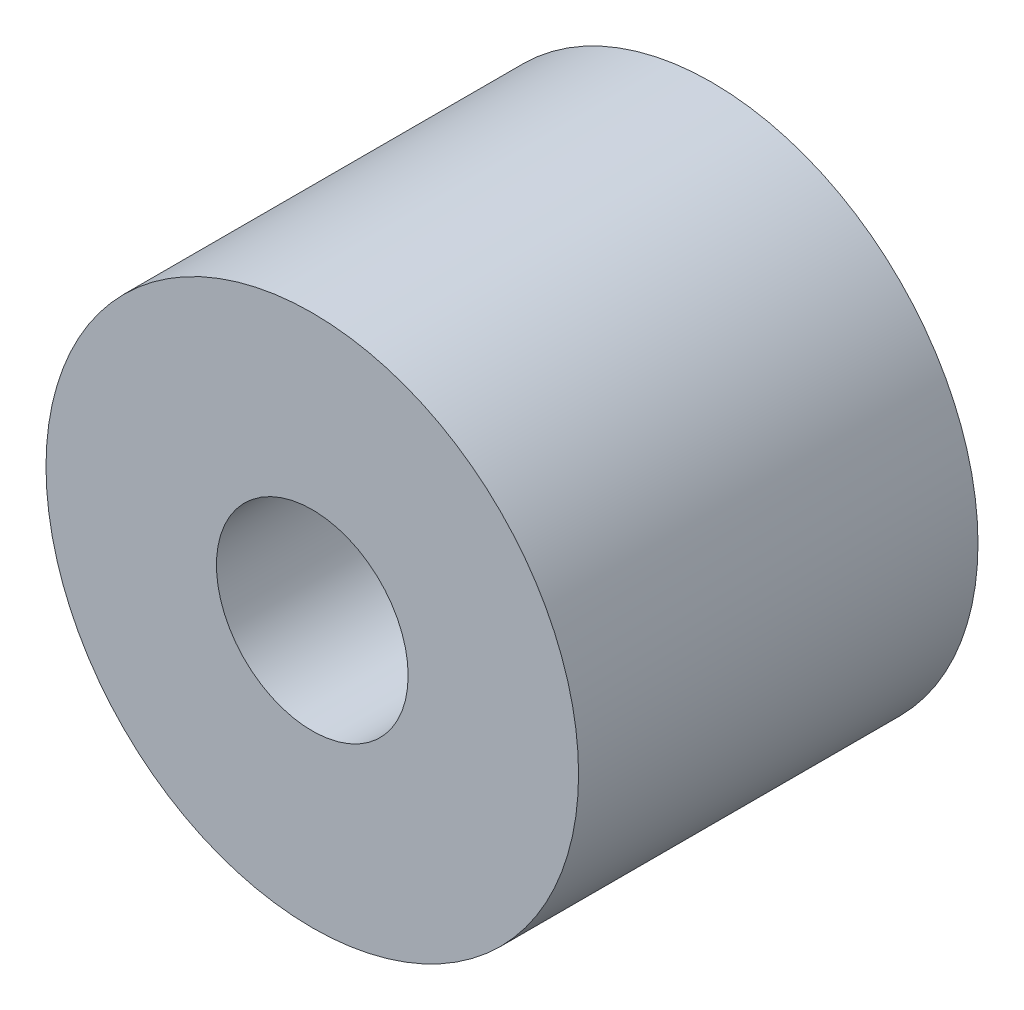
from build123d import *

# Parameters (mm, degrees)
SKETCH1_R           = 3.175
SKETCH1_R_2         = 1.143
EXTRUDE1_DEPTH      = 2.38125
EXTRUDE1_DEPTH_BACK = 2.38125


with BuildPart() as part:
    # Sketch1 → Extrude1 (new body, two sides)
    with BuildSketch(Plane.XY) as extrude1_sk:
        Circle(SKETCH1_R)
        Circle(SKETCH1_R_2, mode=Mode.SUBTRACT)
    extrude(amount=EXTRUDE1_DEPTH)
    extrude(extrude1_sk.sketch, amount=-EXTRUDE1_DEPTH_BACK)


solid = part.part
